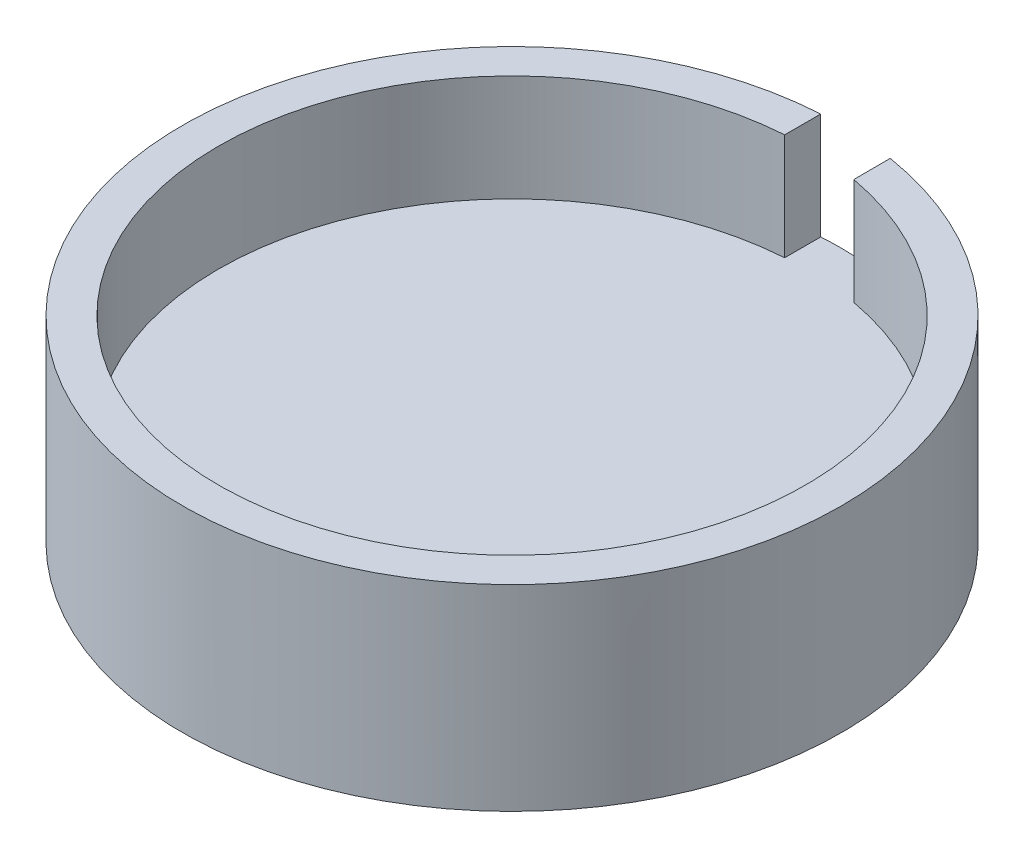
from build123d import *

# Parameters (mm, degrees)
SKETCH1_R           = 58.166
BOSS_EXTRUDE1_DEPTH = 21.971
SKETCH3_R           = 51.816
CUT_EXTRUDE2_DEPTH  = 18.796
CUT_EXTRUDE7_DEPTH  = 18.796
SKETCH8_R           = 58.166
BOSS_EXTRUDE4_DEPTH = 12.7
SKETCH9_R           = 6.477
CUT_EXTRUDE8_DEPTH  = 12.7


with BuildPart() as part:
    # Sketch1 → Boss-Extrude1 (new body)
    with BuildSketch(Plane(origin=(0, 0, 0), x_dir=(1, 0, 0), z_dir=(0, 1, 0))):
        Circle(SKETCH1_R)
    extrude(amount=BOSS_EXTRUDE1_DEPTH)

    # Sketch3 → Cut-Extrude2 (cut)
    with BuildSketch(Plane(origin=(0, 21.971, 0), x_dir=(1, 0, 0), z_dir=(0, 1, 0))):
        Circle(SKETCH3_R)
    extrude(amount=-CUT_EXTRUDE2_DEPTH, mode=Mode.SUBTRACT)

    # Sketch6 → Cut-Extrude7 (cut)
    with BuildSketch(Plane(origin=(0, 21.971, 0), x_dir=(1, 0, 0), z_dir=(0, 1, 0))):
        with BuildLine():
            Line((9.363048829, 50.963037318), (9.340756891, 57.411094892))
            ThreePointArc((9.340756891, 57.411094892), (2.903170649, 58.093503563), (-3.57037671, 58.056317194))
            Line((-3.57037671, 58.056317194), (-3.57037671, 51.692845406))
            ThreePointArc((-3.57037671, 51.692845406), (2.919232353, 51.733702153), (9.363048829, 50.963037318))
        make_face()
    extrude(amount=-CUT_EXTRUDE7_DEPTH, mode=Mode.SUBTRACT)

    # Sketch8 → Boss-Extrude4 (add)
    with BuildSketch(Plane.XZ):
        Circle(SKETCH8_R)
    extrude(amount=BOSS_EXTRUDE4_DEPTH)

    # Sketch9 → Cut-Extrude8 (cut)
    with BuildSketch(Plane.XZ.offset(12.7)):
        with Locations((-29.083, 0)):
            Circle(SKETCH9_R)
        with Locations((29.083, 0)):
            Circle(SKETCH9_R)
    extrude(amount=-CUT_EXTRUDE8_DEPTH, mode=Mode.SUBTRACT)


solid = part.part
